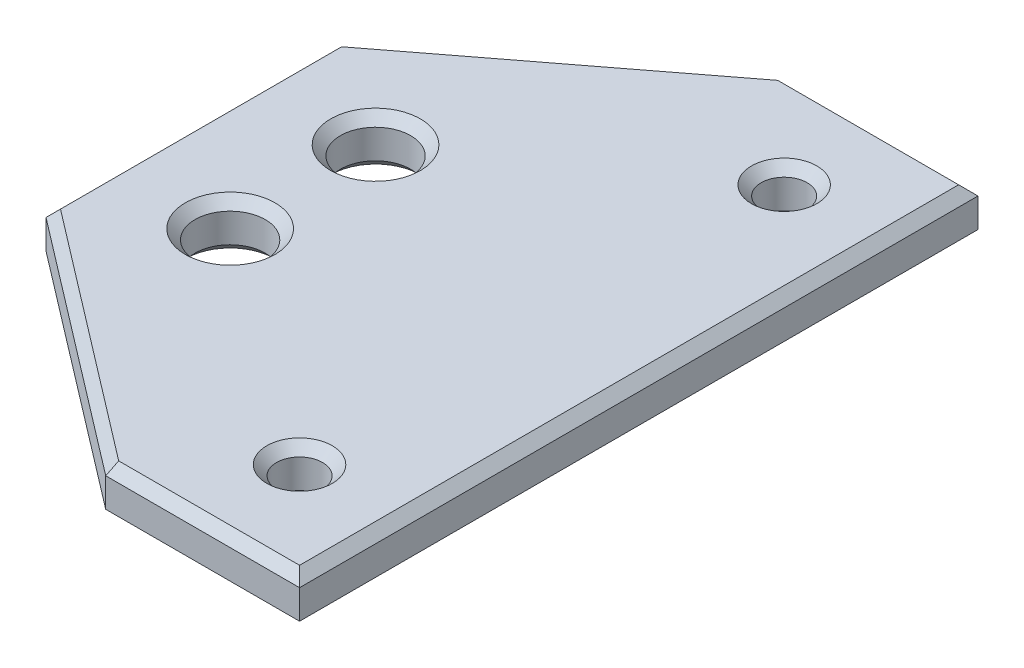
from build123d import *

# Parameters (mm, degrees)
ESBO_O1_R                = 3.625
ESBO_O1_R_2              = 2.375
RESSALTO_EXTRUS_O1_DEPTH = 5
CHANFRO2_SIZE            = 1
ESBO_O2_W                = 6
ESBO_O2_H                = 34
RESSALTO_EXTRUS_O2_DEPTH = 2


with BuildPart() as part:
    # Esboço1 → Ressalto-extrusão1 (new body)
    with BuildSketch(Plane(origin=(0, 0, 0), x_dir=(1, 0, 0), z_dir=(0, 1, 0))):
        Polygon((-23.080933084, -15), (3.080933084, -15), (3.080933084, -35), (23.080933084, -35), (23.080933084, -15), (23.080933084, 15), (23.080933084, 35), (3.080933084, 35), (3.080933084, 15), (-23.080933084, 15), align=None)
        with Locations((-11.580933084, -7.5)):
            Circle(ESBO_O1_R, mode=Mode.SUBTRACT)
        with Locations((-11.580933084, 7.5)):
            Circle(ESBO_O1_R, mode=Mode.SUBTRACT)
        with Locations((13.080933084, -25)):
            Circle(ESBO_O1_R_2, mode=Mode.SUBTRACT)
        with Locations((13.080933084, 25)):
            Circle(ESBO_O1_R_2, mode=Mode.SUBTRACT)
        Polygon((-23.080933084, 15), (3.080933084, 15), (3.080933084, 35), align=None)
        Polygon((3.080933084, -15), (3.080933084, -35), (-23.080933084, -15), align=None)
    extrude(amount=RESSALTO_EXTRUS_O1_DEPTH)

    # Chanfro2
    chanfro2_edges = [part.edges().sort_by_distance(p)[0] for p in [
        (10.705933084, 0, -25),
        (10.705933084, 0, 25),
        (-10, 5, -25),
        (-15.205933084, 0, -7.5),
        (-15.205933084, 0, 7.5),
        (23.080933084, 0, 0),
        (13.080933084, 0, 35),
        (-10, 0, 25),
        (-23.080933084, 0, 0),
        (-10, 0, -25),
        (-23.080933084, 5, 0),
        (13.080933084, 0, -35),
        (-10, 5, 25),
        (13.080933084, 5, 35),
        (23.080933084, 5, 0),
        (-15.205933084, 5, 7.5),
        (-15.205933084, 5, -7.5),
        (10.705933084, 5, 25),
        (10.705933084, 5, -25),
        (13.080933084, 5, -35),
    ]]
    chamfer(chanfro2_edges, length=CHANFRO2_SIZE)

    # Esboço2 → Ressalto-extrusão2 (add)
    with BuildSketch(Plane.XZ):
        with Locations((13.080933084, 0)):
            Rectangle(ESBO_O2_W, ESBO_O2_H)
    extrude(amount=RESSALTO_EXTRUS_O2_DEPTH)


solid = part.part
